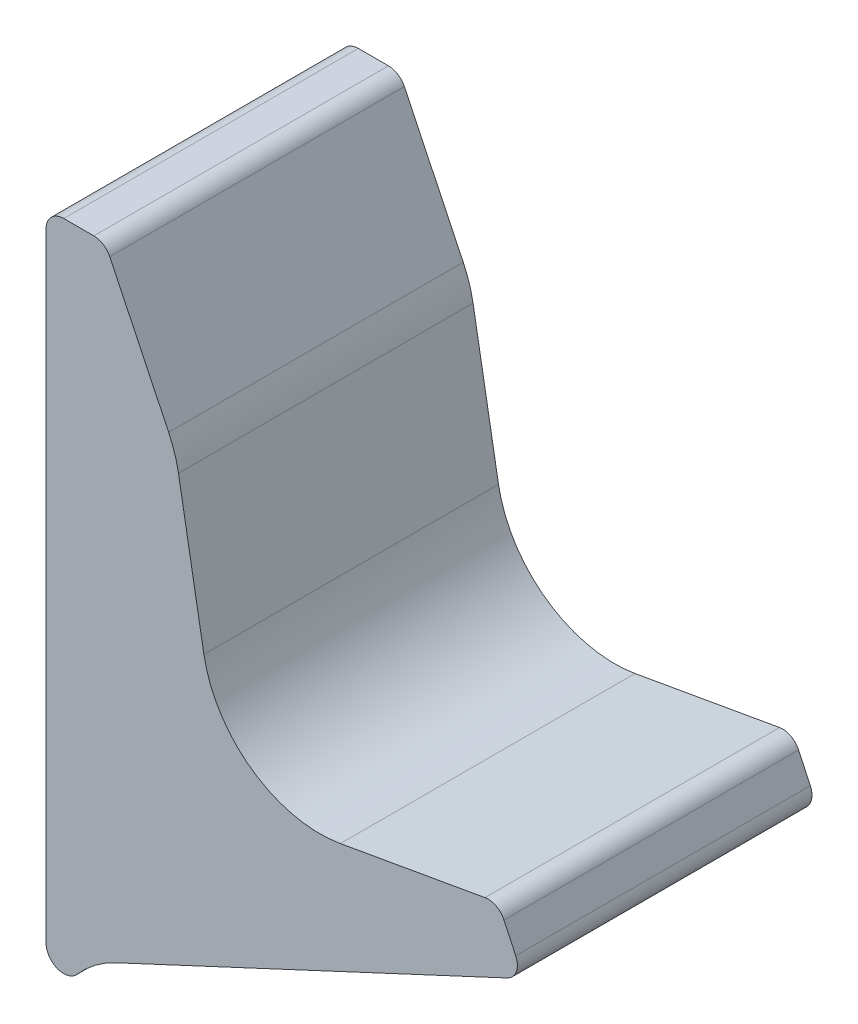
from build123d import *

# Parameters (mm, degrees)
EXTRUDE1_DEPTH = 25


with BuildPart() as part:
    # Sketch1 → Extrude1 (new body, symmetric)
    with BuildSketch(Plane.XY):
        with BuildLine():
            Line((0, -3), (0, -53.784988575))
            Line((0, -53.784988575), (0, -108))
            ThreePointArc((0, -108), (1.951109669, -110.810663458), (5.266552715, -109.96538515))
            ThreePointArc((5.266552715, -109.96538515), (8.33076313, -107.102662764), (11.924538917, -104.941797077))
            Line((11.924538917, -104.941797077), (78.267854785, -74.00540082))
            ThreePointArc((78.267854785, -74.00540082), (79.819077862, -72.312537889), (79.718923361, -70.018622673))
            Line((79.718923361, -70.018622673), (77.733454722, -65.760771437))
            ThreePointArc((77.733454722, -65.760771437), (76.399777201, -64.367593723), (74.493586828, -64.074202964))
            Line((74.493586828, -64.074202964), (49.961112633, -68.399940068))
            ThreePointArc((49.961112633, -68.399940068), (35.016620352, -65.086825893), (26.791994019, -52.176748561))
            Line((26.791994019, -52.176748561), (22.477002989, -27.705218377))
            ThreePointArc((22.477002989, -27.705218377), (21.821246743, -25.05746196), (20.811309078, -22.523560578))
            Line((20.811309078, -22.523560578), (10.816867263, -1.701806797))
            ThreePointArc((10.816867263, -1.701806797), (9.710018402, -0.460848606), (8.11229809, 0))
            Line((8.11229809, 0), (3, 0))
            ThreePointArc((3, 0), (0.878679656, -0.878679656), (0, -3))
        make_face()
    extrude(amount=EXTRUDE1_DEPTH, both=True)


solid = part.part
